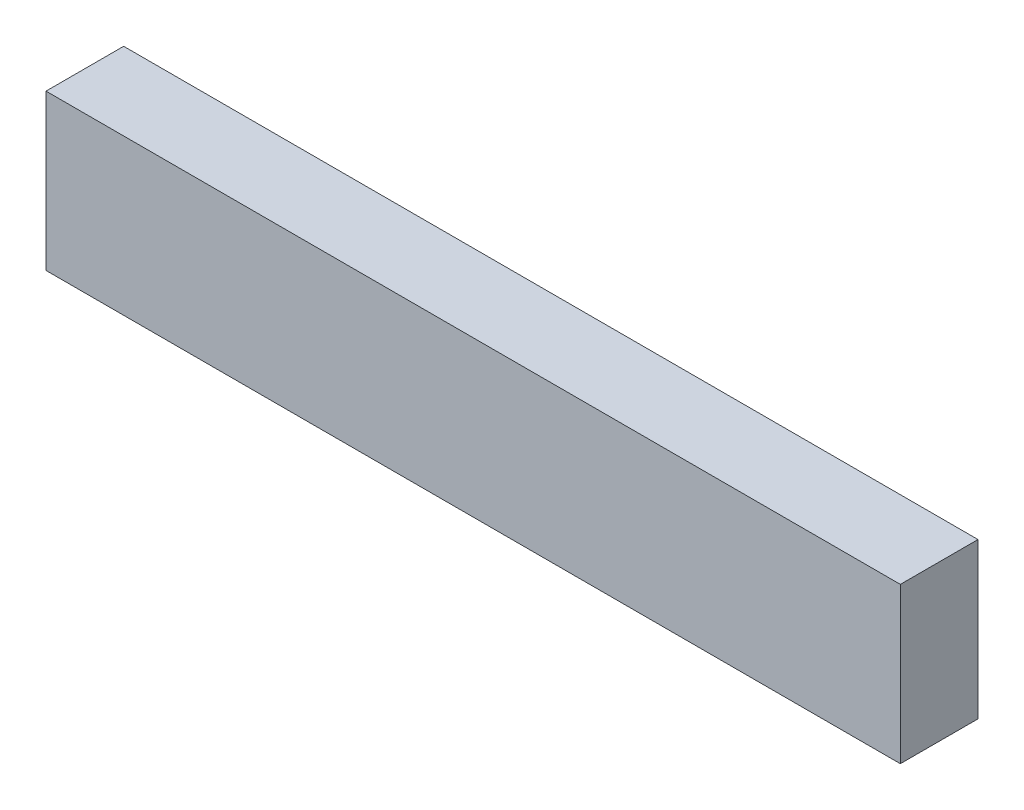
from build123d import *

# Parameters (mm, degrees)
SKETCH_1_W      = 110
SKETCH_1_H      = 20
EXTRUDE_1_DEPTH = 10


with BuildPart() as part:
    # 스케치1 → 보스-돌출1 (new body)
    with BuildSketch(Plane.XY):
        with Locations((55, -10)):
            Rectangle(SKETCH_1_W, SKETCH_1_H)
    extrude(amount=EXTRUDE_1_DEPTH)


solid = part.part
